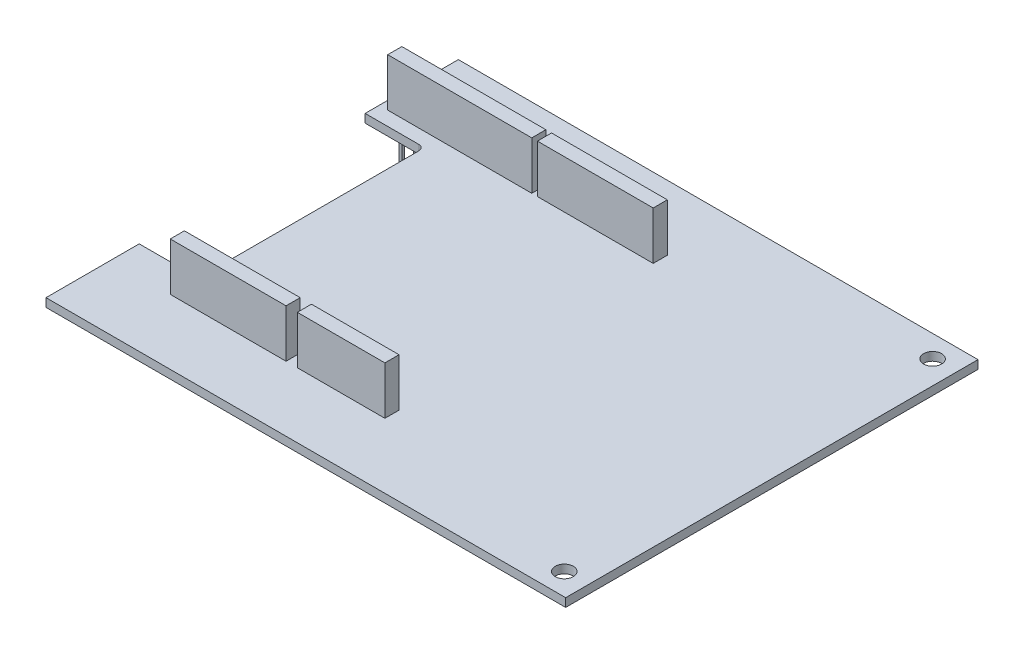
from build123d import *

# Parameters (mm, degrees)
SZKIC1_R                    = 1.6
DODANIE_WYCI_GNI_CIE1_DEPTH = 1.5
SZKIC2_W                    = 15.5
SZKIC2_H                    = 2.5
SZKIC2_W_2                  = 20.5
SZKIC2_W_3                  = 25.5
DODANIE_WYCI_GNI_CIE2_DEPTH = 8.5
SZKIC3_W                    = 0.5
SZKIC3_H                    = 0.5
DODANIE_WYCI_GNI_CIE3_DEPTH = 8.5


with BuildPart() as part:
    # Szkic1 → Dodanie-wyciągnięcie1 (new body)
    with BuildSketch(Plane(origin=(0, 0, 0), x_dir=(1, 0, 0), z_dir=(0, 1, 0))):
        with BuildLine():
            Line((-46, 36.5), (46, 36.5))
            Line((46, 36.5), (46, -36.5))
            Line((46, -36.5), (-46, -36.5))
            Line((-46, -36.5), (-46, -20))
            Line((-46, -20), (-36.5, -20))
            ThreePointArc((-36.5, -20), (-35.792893219, -19.707106781), (-35.5, -19))
            Line((-35.5, -19), (-35.5, 19))
            ThreePointArc((-35.5, 19), (-35.792893219, 19.707106781), (-36.5, 20))
            Line((-36.5, 20), (-46, 20))
            Line((-46, 20), (-46, 36.5))
        make_face()
        with Locations((41.86, 32.6)):
            Circle(SZKIC1_R, mode=Mode.SUBTRACT)
        with Locations((41.86, -32.6)):
            Circle(SZKIC1_R, mode=Mode.SUBTRACT)
    extrude(amount=DODANIE_WYCI_GNI_CIE1_DEPTH)

    # Szkic2 → Dodanie-wyciągnięcie2 (add)
    with BuildSketch(Plane(origin=(0, 1.5, 0), x_dir=(1, 0, 0), z_dir=(0, 1, 0))):
        with Locations((-5.25, -23.75)):
            Rectangle(SZKIC2_W, SZKIC2_H)
        with Locations((-25.25, -23.75)):
            Rectangle(SZKIC2_W_2, SZKIC2_H)
        with Locations((-7.75, 23.75)):
            Rectangle(SZKIC2_W_2, SZKIC2_H)
        with Locations((-31.75, 23.75)):
            Rectangle(SZKIC2_W_3, SZKIC2_H)
    extrude(amount=DODANIE_WYCI_GNI_CIE2_DEPTH)

    # Szkic3 → Dodanie-wyciągnięcie3 (add)
    with BuildSketch(Plane.XZ):
        with Locations((-43.25, -23.75)):
            Rectangle(SZKIC3_W, SZKIC3_H)
        with Locations((-40.694444444, -23.75)):
            Rectangle(SZKIC3_W, SZKIC3_H)
        with Locations((-38.138888889, -23.75)):
            Rectangle(SZKIC3_W, SZKIC3_H)
        with Locations((-35.583333333, -23.75)):
            Rectangle(SZKIC3_W, SZKIC3_H)
        with Locations((-33.027777778, -23.75)):
            Rectangle(SZKIC3_W, SZKIC3_H)
        with Locations((-30.472222222, -23.75)):
            Rectangle(SZKIC3_W, SZKIC3_H)
        with Locations((-27.916666667, -23.75)):
            Rectangle(SZKIC3_W, SZKIC3_H)
        with Locations((-25.361111111, -23.75)):
            Rectangle(SZKIC3_W, SZKIC3_H)
        with Locations((-22.805555556, -23.75)):
            Rectangle(SZKIC3_W, SZKIC3_H)
        with Locations((-20.25, -23.75)):
            Rectangle(SZKIC3_W, SZKIC3_H)
        with Locations((-16.75, -23.75)):
            Rectangle(SZKIC3_W, SZKIC3_H)
        with Locations((-14.178571429, -23.75)):
            Rectangle(SZKIC3_W, SZKIC3_H)
        with Locations((-11.607142857, -23.75)):
            Rectangle(SZKIC3_W, SZKIC3_H)
        with Locations((-9.035714286, -23.75)):
            Rectangle(SZKIC3_W, SZKIC3_H)
        with Locations((-6.464285714, -23.75)):
            Rectangle(SZKIC3_W, SZKIC3_H)
        with Locations((-3.892857143, -23.75)):
            Rectangle(SZKIC3_W, SZKIC3_H)
        with Locations((-1.321428571, -23.75)):
            Rectangle(SZKIC3_W, SZKIC3_H)
        with Locations((1.25, -23.75)):
            Rectangle(SZKIC3_W, SZKIC3_H)
        with Locations((-34.25, 23.75)):
            Rectangle(SZKIC3_W, SZKIC3_H)
        with Locations((-31.678571432, 23.750167466)):
            Rectangle(SZKIC3_W, SZKIC3_H)
        with Locations((-29.107142864, 23.750334931)):
            Rectangle(SZKIC3_W, SZKIC3_H)
        with Locations((-26.535714297, 23.750502397)):
            Rectangle(SZKIC3_W, SZKIC3_H)
        with Locations((-23.964285729, 23.750669862)):
            Rectangle(SZKIC3_W, SZKIC3_H)
        with Locations((-21.392857161, 23.750837328)):
            Rectangle(SZKIC3_W, SZKIC3_H)
        with Locations((-18.821428593, 23.751004794)):
            Rectangle(SZKIC3_W, SZKIC3_H)
        Polygon((-16, 23.501172259), (-16, 24), (-16.000000025, 24.001172259), (-16.500000025, 24.001172259), (-16.500000025, 23.501172259), align=None)
        with Locations((-11.75, 23.75)):
            Rectangle(SZKIC3_W, SZKIC3_H)
        with Locations((-9.15, 23.75)):
            Rectangle(SZKIC3_W, SZKIC3_H)
        with Locations((-6.55, 23.75)):
            Rectangle(SZKIC3_W, SZKIC3_H)
        with Locations((-3.95, 23.75)):
            Rectangle(SZKIC3_W, SZKIC3_H)
        with Locations((-1.35, 23.75)):
            Rectangle(SZKIC3_W, SZKIC3_H)
        with Locations((1.25, 23.75)):
            Rectangle(SZKIC3_W, SZKIC3_H)
    extrude(amount=DODANIE_WYCI_GNI_CIE3_DEPTH)


solid = part.part
